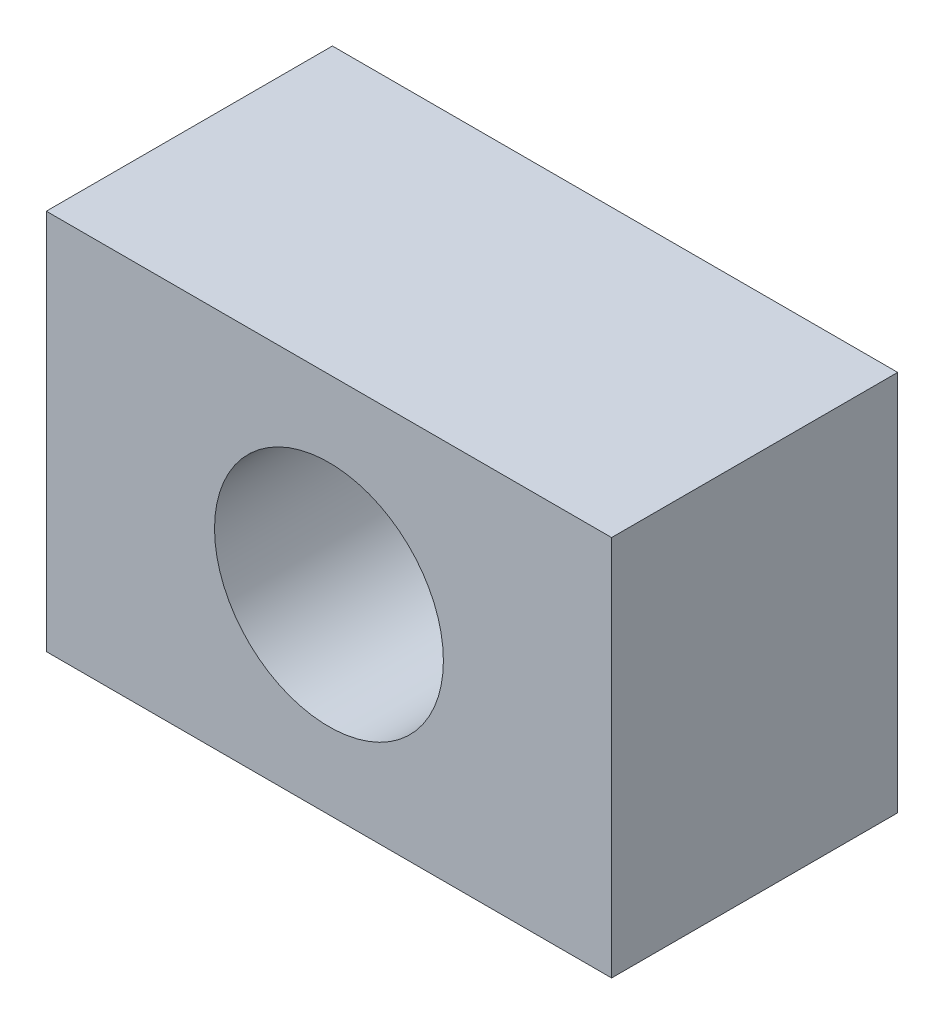
from build123d import *

# Parameters (mm, degrees)
SKETCH1_W           = 29.64
SKETCH1_H           = 20
SKETCH1_R           = 6
BOSS_EXTRUDE1_DEPTH = 15


with BuildPart() as part:
    # Sketch1 → Boss-Extrude1 (new body)
    with BuildSketch(Plane.XY):
        Rectangle(SKETCH1_W, SKETCH1_H)
        Circle(SKETCH1_R, mode=Mode.SUBTRACT)
    extrude(amount=BOSS_EXTRUDE1_DEPTH)


solid = part.part
